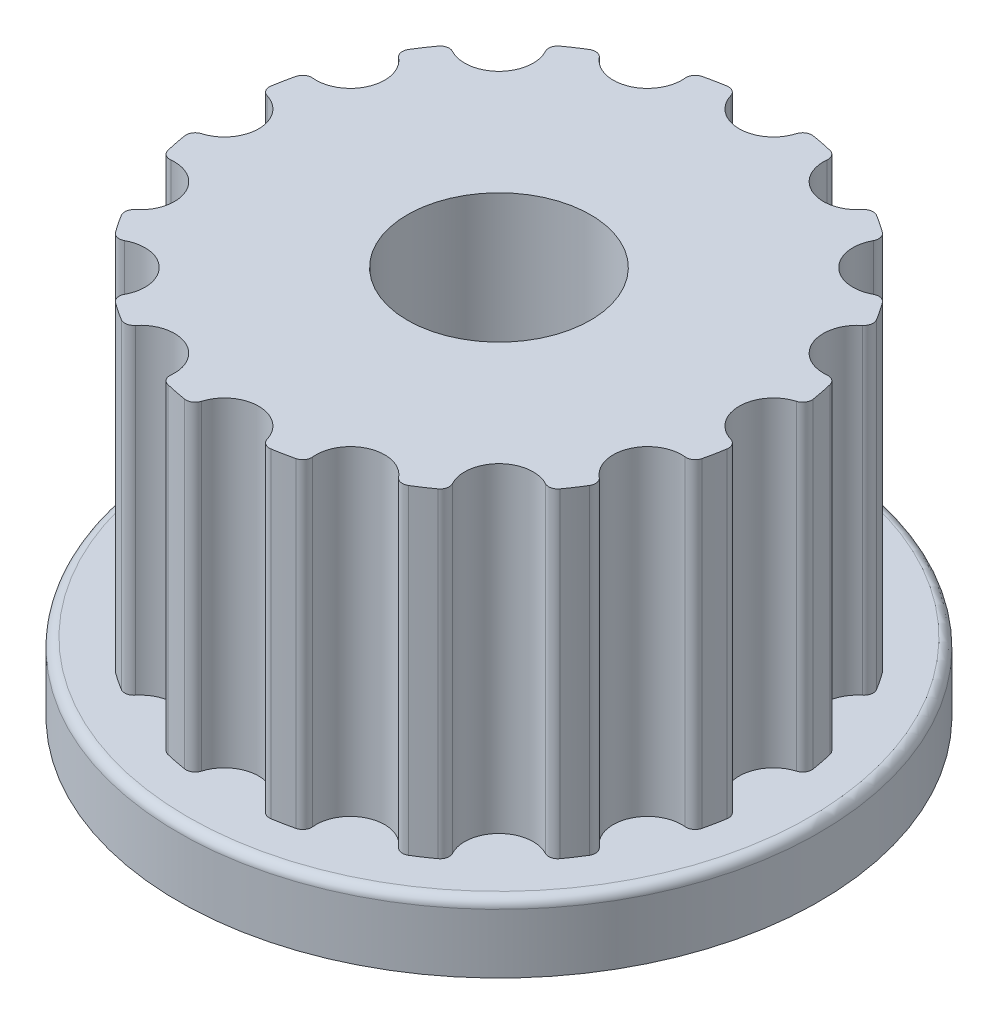
from build123d import *

# Parameters (mm, degrees)
EXTRUDE7_DEPTH = 7
SKETCH4_R      = 7
EXTRUDE8_DEPTH = 1.5
SKETCH3_R      = 2
EXTRUDE9_DEPTH = 8.5
FILLET3_R      = 0.2
FILLET4_R      = 0.2


with BuildPart() as part:
    # Sketch1 → Extrude7 (new body)
    with BuildSketch(Plane(origin=(0, 0, 0), x_dir=(1, 0, 0), z_dir=(0, 1, 0))):
        with BuildLine():
            ThreePointArc((5.953125, -0.748533723), (5.25, 0), (5.953125, 0.748533723))
            ThreePointArc((5.953125, 0.748533723), (5.884711682, 1.170541932), (5.786421796, 1.586607322))
            ThreePointArc((5.786421796, 1.586607322), (4.850367546, 2.00908802), (5.213518888, 2.969717294))
            ThreePointArc((5.213518888, 2.969717294), (4.988817674, 3.333421398), (4.738788328, 3.680201785))
            ThreePointArc((4.738788328, 3.680201785), (3.712310601, 3.712310601), (3.680201785, 4.738788328))
            ThreePointArc((3.680201785, 4.738788328), (3.333421398, 4.988817674), (2.969717294, 5.213518888))
            ThreePointArc((2.969717294, 5.213518888), (2.00908802, 4.850367546), (1.586607322, 5.786421796))
            ThreePointArc((1.586607322, 5.786421796), (1.170541932, 5.884711682), (0.748533723, 5.953125))
            ThreePointArc((0.748533723, 5.953125), (0, 5.25), (-0.748533723, 5.953125))
            ThreePointArc((-0.748533723, 5.953125), (-1.170541932, 5.884711682), (-1.586607322, 5.786421796))
            ThreePointArc((-1.586607322, 5.786421796), (-1.556296582, 5.666525007), (-1.546100594, 5.543277195))
            ThreePointArc((-1.546100594, 5.543277195), (-2.126855986, 4.812622514), (-2.969717294, 5.213518888))
            ThreePointArc((-2.969717294, 5.213518888), (-3.333421398, 4.988817674), (-3.680201785, 4.738788328))
            ThreePointArc((-3.680201785, 4.738788328), (-3.541096256, 4.507848929), (-3.492640687, 4.242640687))
            ThreePointArc((-3.492640687, 4.242640687), (-3.93410441, 3.559043316), (-4.738788328, 3.680201785))
            ThreePointArc((-4.738788328, 3.680201785), (-4.988817674, 3.333421398), (-5.213518888, 2.969717294))
            ThreePointArc((-5.213518888, 2.969717294), (-4.906952305, 2.693077463), (-4.793277195, 2.296100594))
            ThreePointArc((-4.793277195, 2.296100594), (-5.107306124, 1.685830797), (-5.786421796, 1.586607322))
            ThreePointArc((-5.786421796, 1.586607322), (-5.884711682, 1.170541932), (-5.953125, 0.748533723))
            ThreePointArc((-5.953125, 0.748533723), (-5.45334826, 0.513489898), (-5.25, 0))
            ThreePointArc((-5.25, 0), (-5.45334826, -0.513489898), (-5.953125, -0.748533723))
            ThreePointArc((-5.953125, -0.748533723), (-5.884711682, -1.170541932), (-5.786421796, -1.586607322))
            ThreePointArc((-5.786421796, -1.586607322), (-5.107306124, -1.685830797), (-4.793277195, -2.296100594))
            ThreePointArc((-4.793277195, -2.296100594), (-4.906952305, -2.693077463), (-5.213518888, -2.969717294))
            ThreePointArc((-5.213518888, -2.969717294), (-4.988817674, -3.333421398), (-4.738788328, -3.680201785))
            ThreePointArc((-4.738788328, -3.680201785), (-3.93410441, -3.559043316), (-3.492640687, -4.242640687))
            ThreePointArc((-3.492640687, -4.242640687), (-3.541096256, -4.507848929), (-3.680201785, -4.738788328))
            ThreePointArc((-3.680201785, -4.738788328), (-3.333421398, -4.988817674), (-2.969717294, -5.213518888))
            ThreePointArc((-2.969717294, -5.213518888), (-2.126855986, -4.812622514), (-1.546100594, -5.543277195))
            ThreePointArc((-1.546100594, -5.543277195), (-1.556296582, -5.666525007), (-1.586607322, -5.786421796))
            ThreePointArc((-1.586607322, -5.786421796), (-1.170541932, -5.884711682), (-0.748533723, -5.953125))
            ThreePointArc((-0.748533723, -5.953125), (0, -5.25), (0.748533723, -5.953125))
            ThreePointArc((0.748533723, -5.953125), (1.170541932, -5.884711682), (1.586607322, -5.786421796))
            ThreePointArc((1.586607322, -5.786421796), (2.00908802, -4.850367546), (2.969717294, -5.213518888))
            ThreePointArc((2.969717294, -5.213518888), (3.333421398, -4.988817674), (3.680201785, -4.738788328))
            ThreePointArc((3.680201785, -4.738788328), (3.712310601, -3.712310601), (4.738788328, -3.680201785))
            ThreePointArc((4.738788328, -3.680201785), (4.988817674, -3.333421398), (5.213518888, -2.969717294))
            ThreePointArc((5.213518888, -2.969717294), (4.850367546, -2.00908802), (5.786421796, -1.586607322))
            ThreePointArc((5.786421796, -1.586607322), (5.884711682, -1.170541932), (5.953125, -0.748533723))
        make_face()
    extrude(amount=EXTRUDE7_DEPTH)

    # Sketch4 → Extrude8 (add)
    with BuildSketch(Plane.XZ):
        Circle(SKETCH4_R)
    extrude(amount=EXTRUDE8_DEPTH)

    # Sketch3 → Extrude9 (cut)
    with BuildSketch(Plane(origin=(0, 7, 0), x_dir=(-1, 0, 0), z_dir=(0, 1, 0))):
        Circle(SKETCH3_R)
    extrude(amount=-EXTRUDE9_DEPTH, mode=Mode.SUBTRACT)

    # Fillet3
    fillet3_edges = [part.edges().sort_by_distance(p)[0] for p in [
        (-7, 0, 0),
    ]]
    fillet(fillet3_edges, radius=FILLET3_R)

    # Fillet4
    fillet4_edges = [part.edges().sort_by_distance(p)[0] for p in [
        (-5.786421796, 3.5, 1.586607322),
        (-5.953125, 3.5, 0.748533723),
        (-5.953125, 3.5, -0.748533723),
        (-5.786421796, 3.5, -1.586607322),
        (-5.213518888, 3.5, -2.969717294),
        (-4.738788328, 3.5, -3.680201785),
        (-3.680201785, 3.5, -4.738788328),
        (-2.969717294, 3.5, -5.213518888),
        (-1.586607322, 3.5, -5.786421796),
        (-0.748533723, 3.5, -5.953125),
        (0.748533723, 3.5, -5.953125),
        (1.586607322, 3.5, -5.786421796),
        (2.969717294, 3.5, -5.213518888),
        (3.680201785, 3.5, -4.738788328),
        (4.738788328, 3.5, -3.680201785),
        (5.213518888, 3.5, -2.969717294),
        (5.786421796, 3.5, -1.586607322),
        (5.953125, 3.5, -0.748533723),
        (5.953125, 3.5, 0.748533723),
        (5.786421796, 3.5, 1.586607322),
        (5.213518888, 3.5, 2.969717294),
        (4.738788328, 3.5, 3.680201785),
        (3.680201785, 3.5, 4.738788328),
        (2.969717294, 3.5, 5.213518888),
        (1.586607322, 3.5, 5.786421796),
        (0.748533723, 3.5, 5.953125),
        (-0.748533723, 3.5, 5.953125),
        (-1.586607322, 3.5, 5.786421796),
        (-2.969717294, 3.5, 5.213518888),
        (-3.680201785, 3.5, 4.738788328),
        (-4.738788328, 3.5, 3.680201785),
        (-5.213518888, 3.5, 2.969717294),
    ]]
    fillet(fillet4_edges, radius=FILLET4_R)


solid = part.part
